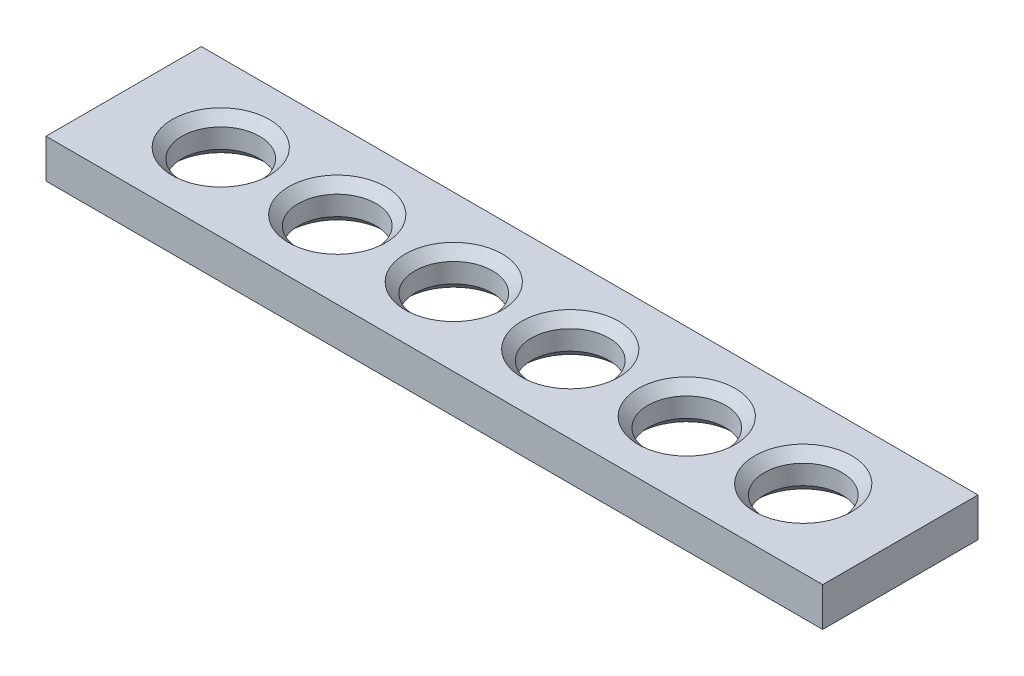
from build123d import *

# Parameters (mm, degrees)
CROQUIS2_W                = 25.4
CROQUIS2_H                = 6.35
SALIENTE_EXTRUIR1_DEPTH   = 127
TALADRO1_D                = 12.7
CHAFL_N1_SIZE             = 1.5875
MATRIZL1_COUNT            = 6
MATRIZL1_PITCH            = 19.05
CHAFL_N1_OF_MATRIZL1_SIZE = 1.5875


with BuildPart() as part:
    # Croquis2 → Saliente-Extruir1 (new body)
    with BuildSketch(Plane(origin=(0, 0, 0), x_dir=(0, 0, -1), z_dir=(1, 0, 0))):
        Rectangle(CROQUIS2_W, CROQUIS2_H)
    extrude(amount=SALIENTE_EXTRUIR1_DEPTH)

    # Taladro1 (through all)
    with Locations(Plane(origin=(0, 3.175, 0), x_dir=(1, 0, 0), z_dir=(0, 1, 0))):
        with Locations((15.875, 0)):
            taladro1 = Hole(TALADRO1_D / 2)

    # Chaflán1
    chafl_n1_edges = [part.edges().sort_by_distance(p)[0] for p in [
        (22.225, 3.175, 0),
        (22.225, -3.175, 0),
    ]]
    chamfer(chafl_n1_edges, length=CHAFL_N1_SIZE)

    # MatrizL1: Taladro1 ×6
    with Locations(*[(i * MATRIZL1_PITCH, 0, 0) for i in range(1, MATRIZL1_COUNT)]):
        add(taladro1, mode=Mode.SUBTRACT)

    # Chaflán1 of MatrizL1
    chafl_n1_of_matrizl1_edges = [part.edges().sort_by_distance(p)[0] for p in [
        (41.275, 3.175, 0),
        (41.275, -3.175, 0),
        (60.325, 3.175, 0),
        (60.325, -3.175, 0),
        (79.375, 3.175, 0),
        (79.375, -3.175, 0),
        (98.425, 3.175, 0),
        (98.425, -3.175, 0),
        (117.475, 3.175, 0),
        (117.475, -3.175, 0),
    ]]
    chamfer(chafl_n1_of_matrizl1_edges, length=CHAFL_N1_OF_MATRIZL1_SIZE)


solid = part.part
